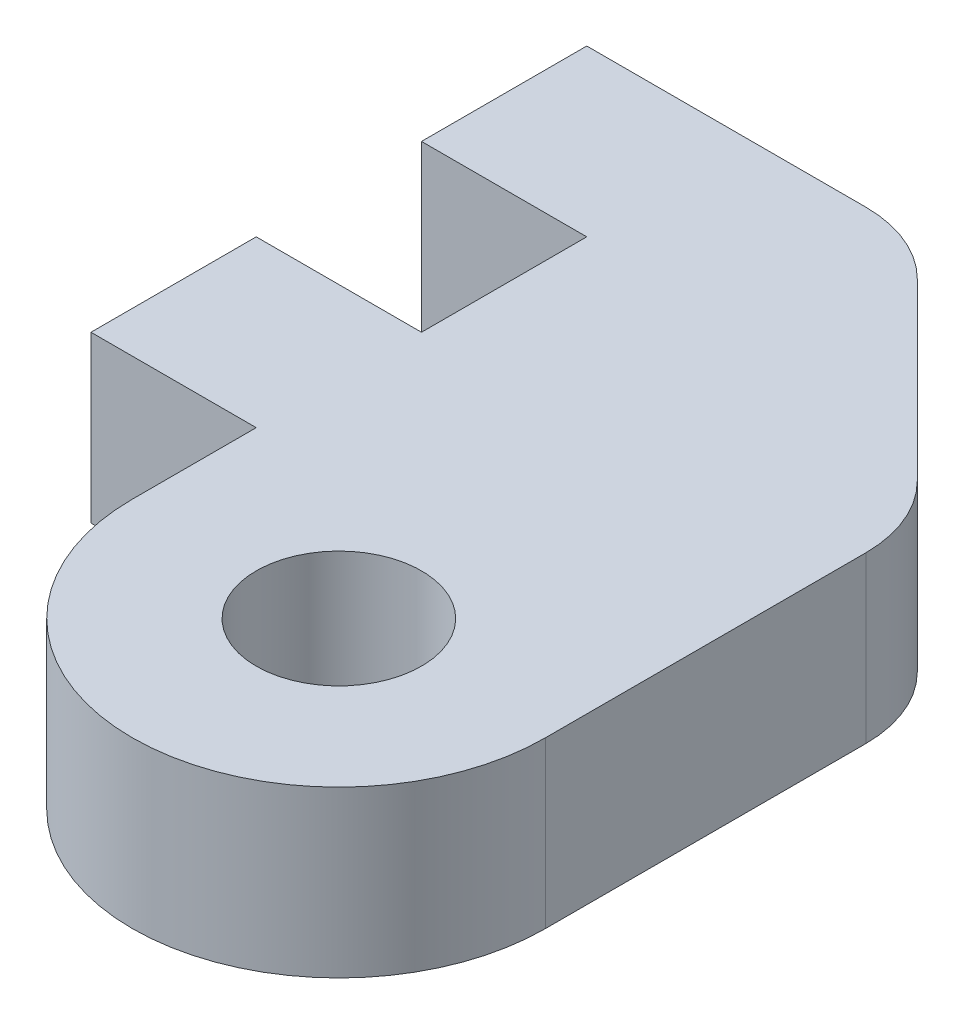
from build123d import *

# Parameters (mm, degrees)
SKETCH1_R           = 2
BOSS_EXTRUDE1_DEPTH = 4
CHAMFER1_SIZE       = 6
FILLET1_R           = 3


with BuildPart() as part:
    # Sketch1 → Boss-Extrude1 (new body)
    with BuildSketch(Plane(origin=(0, 0, 0), x_dir=(1, 0, 0), z_dir=(0, 1, 0))):
        with BuildLine():
            ThreePointArc((-5, 0), (0, -5), (5, 0))
            Line((5, 0), (5, 15))
            Line((5, 15), (-9, 15))
            Line((-9, 15), (-9, 11))
            Line((-9, 11), (-5, 11))
            Line((-5, 11), (-5, 7))
            Line((-5, 7), (-9, 7))
            Line((-9, 7), (-9, 3))
            Line((-9, 3), (-5, 3))
            Line((-5, 3), (-5, 0))
        make_face()
        Circle(SKETCH1_R, mode=Mode.SUBTRACT)
    extrude(amount=BOSS_EXTRUDE1_DEPTH)

    # Chamfer1
    chamfer1_edges = [part.edges().sort_by_distance(p)[0] for p in [
        (5, 2, -15),
    ]]
    chamfer(chamfer1_edges, length=CHAMFER1_SIZE)

    # Fillet1
    fillet1_edges = [part.edges().sort_by_distance(p)[0] for p in [
        (-1, 2, -15),
        (5, 2, -9),
    ]]
    fillet(fillet1_edges, radius=FILLET1_R)


solid = part.part
